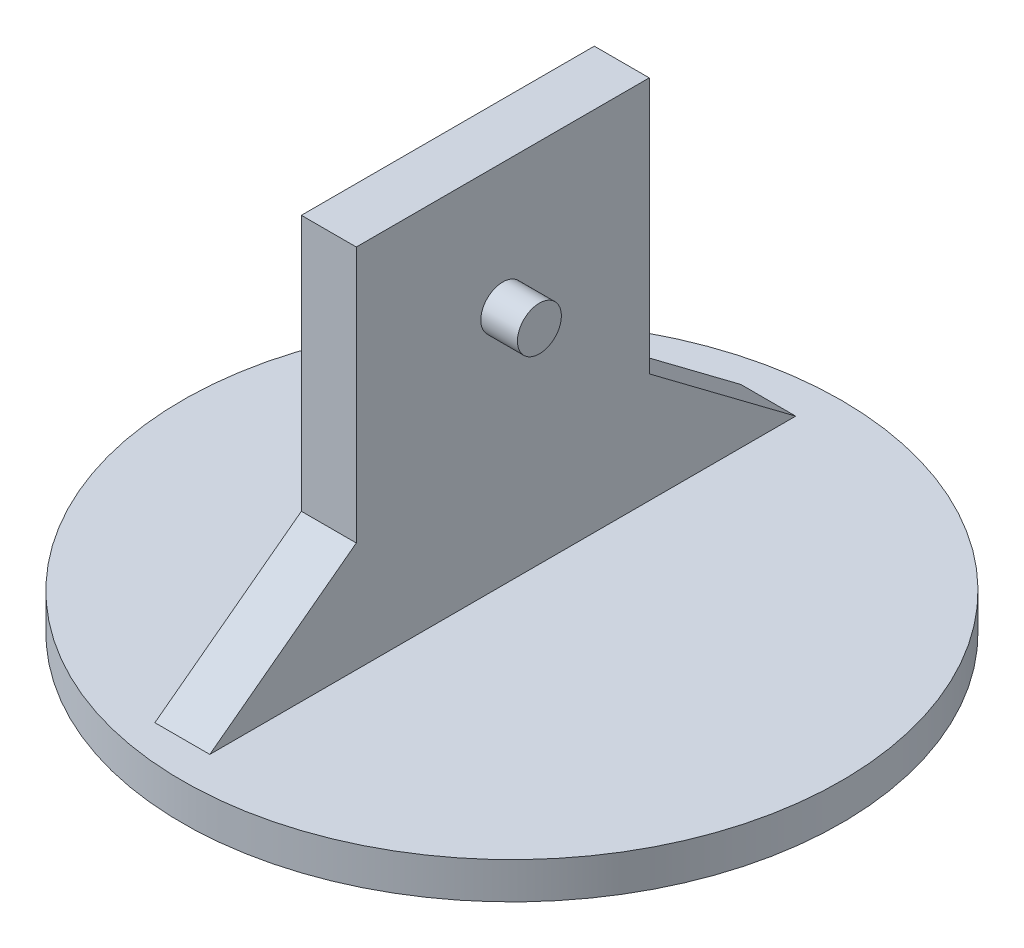
from build123d import *

# Parameters (mm, degrees)
SKETCH1_W           = 80
SKETCH1_H           = 100
BOSS_EXTRUDE1_DEPTH = 15
SKETCH3_R           = 90
BOSS_EXTRUDE2_DEPTH = 10
SKETCH2_R           = 6
BOSS_EXTRUDE3_DEPTH = 10
SKETCH4_R           = 5
BOSS_EXTRUDE4_DEPTH = 10


with BuildPart() as part:
    # Sketch1 → Boss-Extrude1 (new body)
    with BuildSketch(Plane(origin=(0, 0, 0), x_dir=(0, 0, -1), z_dir=(1, 0, 0))):
        Polygon((40, -20), (40, -50), (80, -50), align=None)
        Rectangle(SKETCH1_W, SKETCH1_H)
        Polygon((-80, -50), (-40, -50), (-40, -20), align=None)
    extrude(amount=BOSS_EXTRUDE1_DEPTH)

    # Sketch3 → Boss-Extrude2 (add)
    with BuildSketch(Plane.XZ.offset(50)):
        with Locations((17.5, 0)):
            Circle(SKETCH3_R)
    extrude(amount=BOSS_EXTRUDE2_DEPTH)

    # Sketch2 → Boss-Extrude3 (add)
    with BuildSketch(Plane(origin=(15, 0, 0), x_dir=(0, 0, -1), z_dir=(1, 0, 0))):
        with Locations((0, 15.728916746)):
            Circle(SKETCH2_R)
    extrude(amount=BOSS_EXTRUDE3_DEPTH)

    # Sketch4 → Boss-Extrude4 (add)
    with BuildSketch(Plane.XZ.offset(60)):
        with Locations((17.5, 0)):
            Circle(SKETCH4_R)
    extrude(amount=BOSS_EXTRUDE4_DEPTH)


solid = part.part
